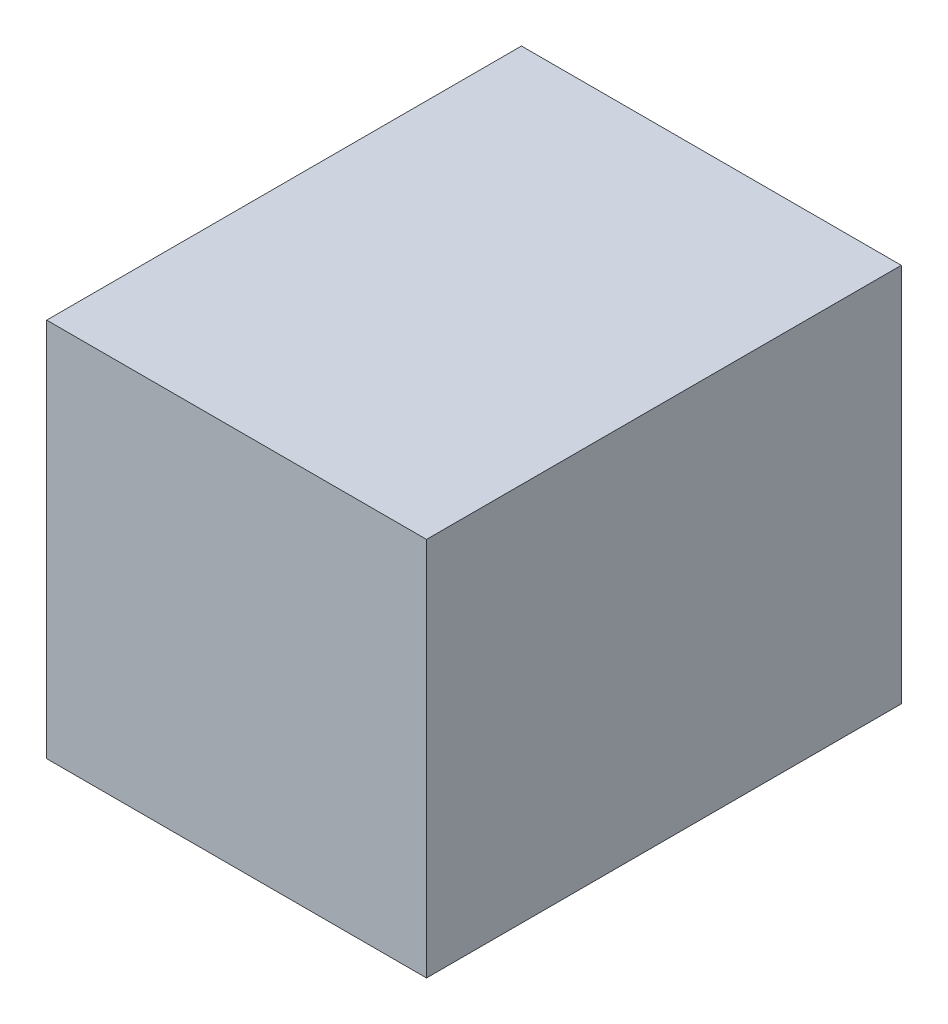
from build123d import *

# Parameters (mm, degrees)
SKETCH1_W           = 2.4
SKETCH1_H           = 2.4
BOSS_EXTRUDE1_DEPTH = 3


with BuildPart() as part:
    # Sketch1 → Boss-Extrude1 (new body)
    with BuildSketch(Plane.XY):
        with Locations((0.077419355, -0.064516129)):
            Rectangle(SKETCH1_W, SKETCH1_H)
    extrude(amount=BOSS_EXTRUDE1_DEPTH)


solid = part.part
